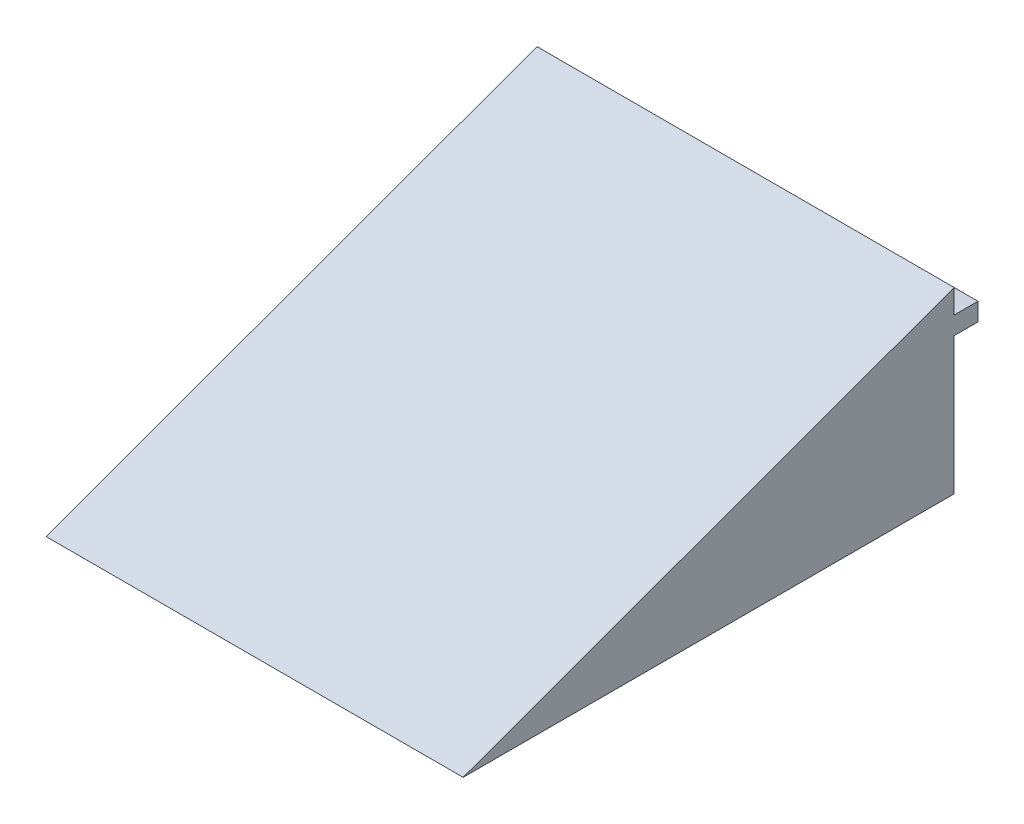
from build123d import *

# Parameters (mm, degrees)
BOSS_EXTRUDE1_DEPTH = 350
SKETCH3_W           = 350
SKETCH3_H           = 15
BOSS_EXTRUDE2_DEPTH = 20


with BuildPart() as part:
    # Sketch1 → Boss-Extrude1 (new body)
    with BuildSketch(Plane(origin=(0, 0, 0), x_dir=(0, 0, -1), z_dir=(1, 0, 0))):
        Polygon((0, 0), (412, 0), (412, 149.955736518), align=None)
    extrude(amount=-BOSS_EXTRUDE1_DEPTH)

    # Sketch3 → Boss-Extrude2 (add)
    with BuildSketch(Plane(origin=(0, 0, -412), x_dir=(-1, 0, 0), z_dir=(0, 0, -1))):
        with Locations((175, 122.455736518)):
            Rectangle(SKETCH3_W, SKETCH3_H)
    extrude(amount=BOSS_EXTRUDE2_DEPTH)


solid = part.part
